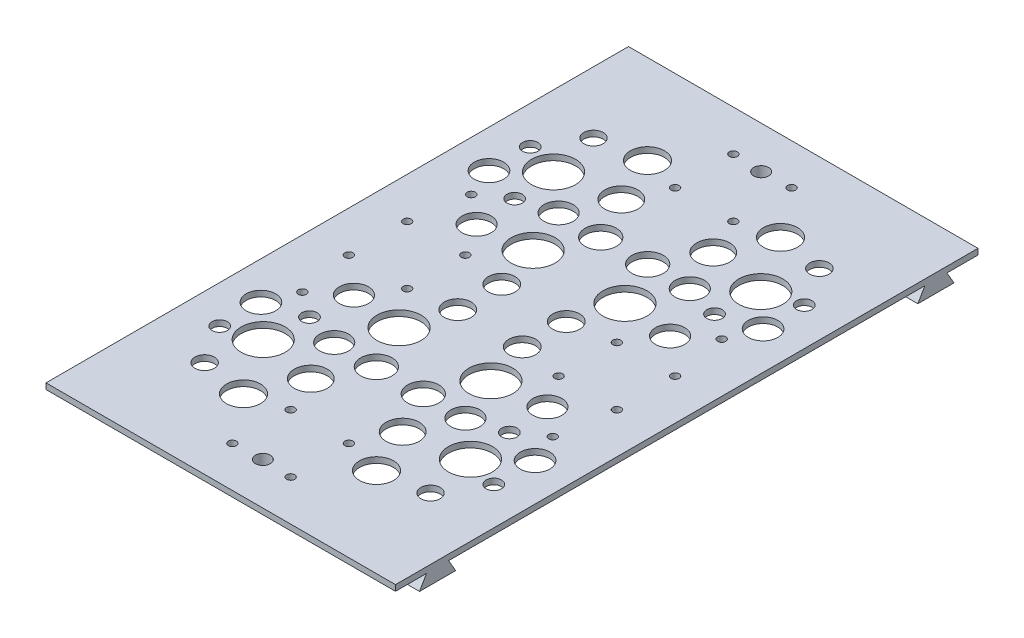
from build123d import *

# Parameters (mm, degrees)
SKETCH3_W                 = 120
SKETCH3_H                 = 200
SKETCH3_R                 = 1.38
BOSS_EXTRUDE1_DEPTH       = 2
BOSS_EXTRUDE2_DEPTH       = 120
SKETCH5_R                 = 1.38
CUT_EXTRUDE1_DEPTH        = 7.16
SKETCH7_R                 = 4.998737833
SKETCH7_R_2               = 7.554686589
SKETCH7_R_3               = 5.693928521
SKETCH7_R_4               = 3.338756268
SKETCH7_R_5               = 5.843083046
SKETCH7_R_6               = 5.380127949
SKETCH7_R_7               = 4.59382227
SKETCH7_R_8               = 2.636652122
SKETCH7_R_9               = 5.065111982
CUT_EXTRUDE2_DEPTH        = 7.16
MIRROR2_COPY_1_SKETCH_R   = 4.998737833
MIRROR2_COPY_1_SKETCH_R_2 = 7.554686589
MIRROR2_COPY_1_SKETCH_R_3 = 5.693928521
MIRROR2_COPY_1_SKETCH_R_4 = 3.338756268
MIRROR2_COPY_1_SKETCH_R_5 = 5.843083046
MIRROR2_COPY_1_SKETCH_R_6 = 5.380127949
MIRROR2_COPY_1_SKETCH_R_7 = 4.59382227
MIRROR2_COPY_1_SKETCH_R_8 = 2.636652122
MIRROR2_COPY_1_SKETCH_R_9 = 5.065111982
MIRROR2_COPY_1_DEPTH      = 7.16
SKETCH8_R                 = 2.55
CUT_EXTRUDE3_DEPTH        = 7.16


with BuildPart() as part:
    # Sketch3 → Boss-Extrude1 (new body)
    with BuildSketch(Plane(origin=(0, 0, 0), x_dir=(1, 0, 0), z_dir=(0, 1, 0))):
        with Locations((1e-09, 0)):
            Rectangle(SKETCH3_W, SKETCH3_H)
        with Locations((-43, 29)):
            Circle(SKETCH3_R, mode=Mode.SUBTRACT)
        with Locations((43, 29)):
            Circle(SKETCH3_R, mode=Mode.SUBTRACT)
        with Locations((43, -29)):
            Circle(SKETCH3_R, mode=Mode.SUBTRACT)
        with Locations((-43, -29)):
            Circle(SKETCH3_R, mode=Mode.SUBTRACT)
    extrude(amount=BOSS_EXTRUDE1_DEPTH)

    # Sketch4 → Boss-Extrude2 (add)
    with BuildSketch(Plane.ZY.offset(59.999999999)):
        Polygon((-89.35, 0), (-91.75177712, -4.16), (-79.34822288, -4.16), (-81.75, 0), align=None)
        Polygon((81.75, 0), (79.34822288, -4.16), (91.75177712, -4.16), (89.35, 0), align=None)
    extrude(amount=-BOSS_EXTRUDE2_DEPTH)

    # Sketch5 → Cut-Extrude1 (cut, through all)
    with BuildSketch(Plane(origin=(0, 2, 0), x_dir=(1, 0, 0), z_dir=(0, 1, 0))):
        with Locations((-10, -86)):
            Circle(SKETCH5_R)
        with Locations((10, -86)):
            Circle(SKETCH5_R)
        with Locations((-45.999999999, 10)):
            Circle(SKETCH5_R)
        with Locations((-45.999999999, -10)):
            Circle(SKETCH5_R)
        with Locations((-25.999999999, 10)):
            Circle(SKETCH5_R)
        with Locations((-25.999999999, -10)):
            Circle(SKETCH5_R)
        with Locations((26.000000001, 10)):
            Circle(SKETCH5_R)
        with Locations((26.000000001, -10)):
            Circle(SKETCH5_R)
        with Locations((46.000000001, 10)):
            Circle(SKETCH5_R)
        with Locations((46.000000001, -10)):
            Circle(SKETCH5_R)
        with Locations((-10, -66)):
            Circle(SKETCH5_R)
        with Locations((10, -66)):
            Circle(SKETCH5_R)
        with Locations((-10, 86)):
            Circle(SKETCH5_R)
        with Locations((10, 86)):
            Circle(SKETCH5_R)
        with Locations((-10, 66)):
            Circle(SKETCH5_R)
        with Locations((10, 66)):
            Circle(SKETCH5_R)
    extrude(amount=-CUT_EXTRUDE1_DEPTH, mode=Mode.SUBTRACT)

    # Sketch7 → Cut-Extrude2 (cut, through all)
    with BuildSketch(Plane(origin=(0, 2, 0), x_dir=(1, 0, 0), z_dir=(0, 1, 0))):
        with Locations((-22.521130628, -38.521841888)):
            Circle(SKETCH7_R)
        with Locations((-35.576157364, -49.846684357)):
            Circle(SKETCH7_R_2)
        with Locations((-15.770265305, -53.307052889)):
            Circle(SKETCH7_R_3)
        with Locations((-38.779208604, -66.765189198)):
            Circle(SKETCH7_R_4)
        with Locations((-22.835709586, -69.350579721)):
            Circle(SKETCH7_R_5)
        with Locations((-15.770265305, -23.019185403)):
            Circle(SKETCH7_R_2)
        with Locations((-8.050498584, -38.521841888)):
            Circle(SKETCH7_R_6)
        with Locations((-11.079773886, -7.545708078)):
            Circle(SKETCH7_R_7)
        with Locations((-34.317841534, -35.218762834)):
            Circle(SKETCH7_R_8)
        with Locations((-33.216815183, -21.062709748)):
            Circle(SKETCH7_R)
        with Locations((-47.058289312, -39.150999803)):
            Circle(SKETCH7_R_9)
        with Locations((-47.058289312, -53.307052889)):
            Circle(SKETCH7_R_8)
    cut_extrude2 = extrude(amount=-CUT_EXTRUDE2_DEPTH, mode=Mode.SUBTRACT)

    # Mirror1: Cut-Extrude2 across plane
    add(cut_extrude2.mirror(Plane.XY), mode=Mode.SUBTRACT)

    # Mirror2: Cut-Extrude2 across plane
    add(cut_extrude2.mirror(Plane(origin=(0, 0, 0), x_dir=(0, 0, 1), z_dir=(1, 0, 0))), mode=Mode.SUBTRACT)

    # Mirror2 copy 1 sketch → Mirror2 copy 1 (cut, through all)
    with BuildSketch(Plane(origin=(0, 2, 0), x_dir=(-1, 0, 0), z_dir=(0, 1, 0))):
        with Locations((-22.521130628, -38.521841888)):
            Circle(MIRROR2_COPY_1_SKETCH_R)
        with Locations((-35.576157364, -49.846684357)):
            Circle(MIRROR2_COPY_1_SKETCH_R_2)
        with Locations((-15.770265305, -53.307052889)):
            Circle(MIRROR2_COPY_1_SKETCH_R_3)
        with Locations((-38.779208604, -66.765189198)):
            Circle(MIRROR2_COPY_1_SKETCH_R_4)
        with Locations((-22.835709586, -69.350579721)):
            Circle(MIRROR2_COPY_1_SKETCH_R_5)
        with Locations((-15.770265305, -23.019185403)):
            Circle(MIRROR2_COPY_1_SKETCH_R_2)
        with Locations((-8.050498584, -38.521841888)):
            Circle(MIRROR2_COPY_1_SKETCH_R_6)
        with Locations((-11.079773886, -7.545708078)):
            Circle(MIRROR2_COPY_1_SKETCH_R_7)
        with Locations((-34.317841534, -35.218762834)):
            Circle(MIRROR2_COPY_1_SKETCH_R_8)
        with Locations((-33.216815183, -21.062709748)):
            Circle(MIRROR2_COPY_1_SKETCH_R)
        with Locations((-47.058289312, -39.150999803)):
            Circle(MIRROR2_COPY_1_SKETCH_R_9)
        with Locations((-47.058289312, -53.307052889)):
            Circle(MIRROR2_COPY_1_SKETCH_R_8)
    extrude(amount=-MIRROR2_COPY_1_DEPTH, mode=Mode.SUBTRACT)

    # Sketch8 → Cut-Extrude3 (cut, through all)
    with BuildSketch(Plane.XZ.offset(4.16)):
        with Locations((1e-09, 85.55)):
            Circle(SKETCH8_R)
    cut_extrude3 = extrude(amount=-CUT_EXTRUDE3_DEPTH, mode=Mode.SUBTRACT)

    # Mirror3: Cut-Extrude3 across plane
    add(cut_extrude3.mirror(Plane.XY), mode=Mode.SUBTRACT)


solid = part.part
